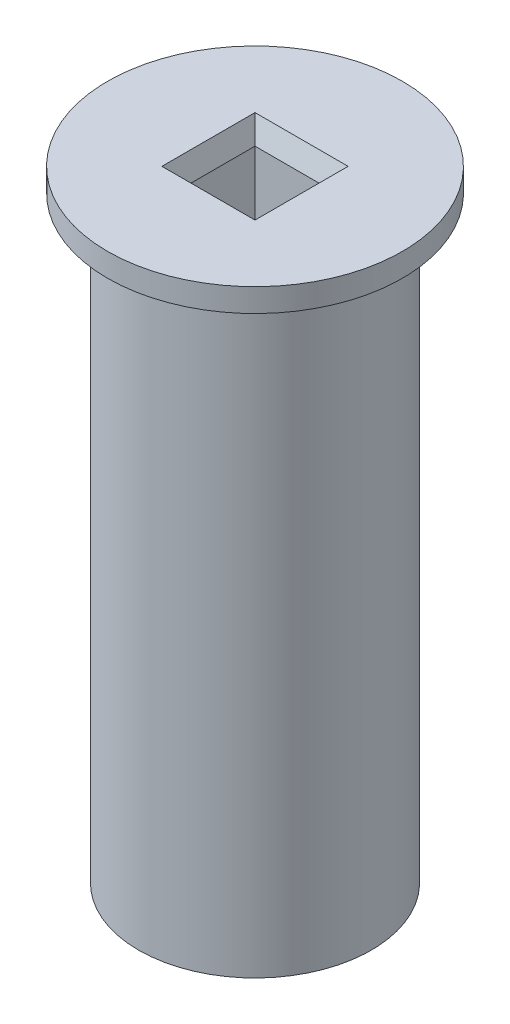
from build123d import *

# Parameters (mm, degrees)
SKETCH_1_R          = 15
SKETCH_1_W          = 10
SKETCH_1_H          = 10
EXTRUDE_1_DEPTH     = 80
SKETCH1_R           = 19
SKETCH1_W           = 10
SKETCH1_H           = 10
BOSS_EXTRUDE1_DEPTH = 3
CHAMFER1_SIZE       = 1
CHAMFER1_SIZE2      = 2.747477419


with BuildPart() as part:
    # Эскиз1 → Бобышка-Вытянуть1 (new body)
    with BuildSketch(Plane(origin=(0, 0, 0), x_dir=(1, 0, 0), z_dir=(0, 1, 0))):
        Circle(SKETCH_1_R)
        Rectangle(SKETCH_1_W, SKETCH_1_H, mode=Mode.SUBTRACT)
    extrude(amount=EXTRUDE_1_DEPTH)

    # Sketch1 → Boss-Extrude1 (add)
    with BuildSketch(Plane(origin=(0, 80, 0), x_dir=(1, 0, 0), z_dir=(0, 1, 0))):
        Circle(SKETCH1_R)
        Rectangle(SKETCH1_W, SKETCH1_H, mode=Mode.SUBTRACT)
    extrude(amount=-BOSS_EXTRUDE1_DEPTH)

    # Chamfer1
    chamfer1_edges = [part.edges().sort_by_distance(p)[0] for p in [
        (0, 80, -5),
        (-5, 80, 0),
        (0, 80, 5),
        (5, 80, 0),
    ]]
    chamfer1_side = [part.faces().sort_by_distance(p)[0] for p in [
        (-18.462598846, 80, 0),
    ]]
    chamfer(chamfer1_edges, length=CHAMFER1_SIZE, length2=CHAMFER1_SIZE2, reference=chamfer1_side[0])


solid = part.part
